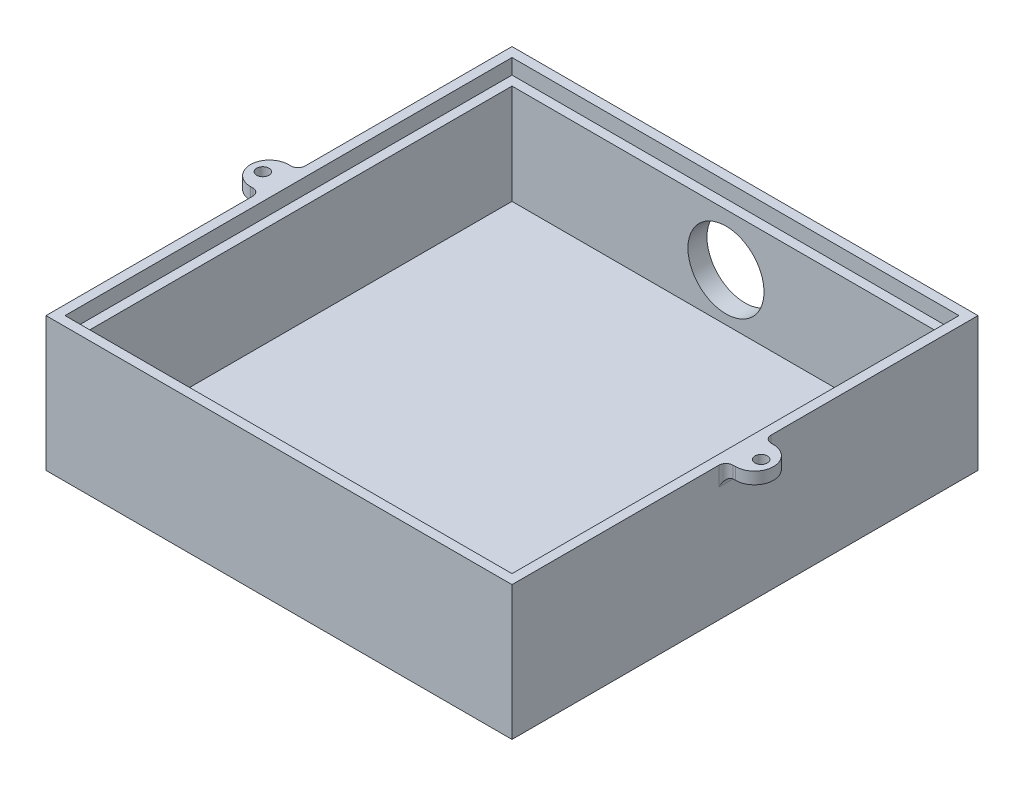
from build123d import *

# Parameters (mm, degrees)
SKETCH1_W           = 98
SKETCH1_H           = 98
BOSS_EXTRUDE1_DEPTH = 30
SKETCH2_W           = 94
SKETCH2_H           = 94
CUT_EXTRUDE1_DEPTH  = 5
SKETCH3_W           = 90
SKETCH3_H           = 90
CUT_EXTRUDE2_DEPTH  = 21
SKETCH4_W           = 98
SKETCH4_H           = 98
SKETCH4_W_2         = 94
SKETCH4_H_2         = 94
CUT_EXTRUDE3_DEPTH  = 1.8
SKETCH5_R           = 1.3
BOSS_EXTRUDE2_DEPTH = 2.5
FILLET1_R           = 1.5
FILLET2_R           = 1.5
CUT_EXTRUDE4_REACH  = 100
SKETCH6_R           = 8
SKETCH7_R           = 1.968352886
CUT_EXTRUDE5_DEPTH  = 1


with BuildPart() as part:
    # Sketch1 → Boss-Extrude1 (new body)
    with BuildSketch(Plane(origin=(0, 0, 0), x_dir=(1, 0, 0), z_dir=(0, 1, 0))):
        Rectangle(SKETCH1_W, SKETCH1_H)
    extrude(amount=BOSS_EXTRUDE1_DEPTH)

    # Sketch2 → Cut-Extrude1 (cut)
    with BuildSketch(Plane(origin=(0, 30, 0), x_dir=(1, 0, 0), z_dir=(0, 1, 0))):
        Rectangle(SKETCH2_W, SKETCH2_H)
    extrude(amount=-CUT_EXTRUDE1_DEPTH, mode=Mode.SUBTRACT)

    # Sketch3 → Cut-Extrude2 (cut)
    with BuildSketch(Plane(origin=(0, 25, 0), x_dir=(1, 0, 0), z_dir=(0, 1, 0))):
        Rectangle(SKETCH3_W, SKETCH3_H)
    extrude(amount=-CUT_EXTRUDE2_DEPTH, mode=Mode.SUBTRACT)

    # Sketch4 → Cut-Extrude3 (cut)
    with BuildSketch(Plane(origin=(0, 30, 0), x_dir=(1, 0, 0), z_dir=(0, 1, 0))):
        Rectangle(SKETCH4_W, SKETCH4_H)
        Rectangle(SKETCH4_W_2, SKETCH4_H_2, mode=Mode.SUBTRACT)
    extrude(amount=-CUT_EXTRUDE3_DEPTH, mode=Mode.SUBTRACT)

    # Sketch5 → Boss-Extrude2 (add)
    with BuildSketch(Plane(origin=(0, 28.2, 0), x_dir=(1, 0, 0), z_dir=(0, 1, 0))):
        with BuildLine():
            Line((-49, 4), (-51, 4))
            ThreePointArc((-51, 4), (-55, 0), (-51, -4))
            Line((-51, -4), (-49, -4))
            Line((-49, -4), (-49, 4))
        make_face()
        with Locations((-52.4, 0)):
            Circle(SKETCH5_R, mode=Mode.SUBTRACT)
        with BuildLine():
            Line((49, 4), (49, -4))
            Line((49, -4), (51, -4))
            ThreePointArc((51, -4), (55, 0), (51, 4))
            Line((51, 4), (49, 4))
        make_face()
        with Locations((52.4, 0)):
            Circle(SKETCH5_R, mode=Mode.SUBTRACT)
    extrude(amount=-BOSS_EXTRUDE2_DEPTH)

    # Fillet1
    fillet1_edges = [part.edges().sort_by_distance(p)[0] for p in [
        (-49, 25.7, 0),
        (-49, 26.95, -4),
        (-49, 26.95, 4),
    ]]
    fillet(fillet1_edges, radius=FILLET1_R)

    # Fillet2
    fillet2_edges = [part.edges().sort_by_distance(p)[0] for p in [
        (49, 26.95, -4),
        (49, 25.7, 0),
        (49, 26.95, 4),
    ]]
    fillet(fillet2_edges, radius=FILLET2_R)

    # Sketch6 → Cut-Extrude4 (cut, up to next)
    with BuildSketch(Plane(origin=(0, 0, -49), x_dir=(-1, 0, 0), z_dir=(0, 0, -1)), mode=Mode.PRIVATE) as cut_extrude4_sk1:
        with Locations((0, 14)):
            Circle(SKETCH6_R)
    cut_extrude4_tool1 = extrude(cut_extrude4_sk1.sketch, amount=-CUT_EXTRUDE4_REACH, mode=Mode.PRIVATE) & part.part
    add(cut_extrude4_tool1.solids().sort_by_distance((0, 14, -49))[0], mode=Mode.SUBTRACT)

    # Sketch7 → Cut-Extrude5 (cut)
    with BuildSketch(Plane.XZ):
        with BuildLine():
            Line((-4, -10), (-1, -10))
            Line((-1, -10), (1, -10))
            ThreePointArc((1, -10), (6, -5), (1, 0))
            ThreePointArc((1, 0), (6, 5), (1, 10))
            Line((1, 10), (-4, 10))
            Line((-4, 10), (-4, -10))
        make_face()
        with Locations((1, 5)):
            Circle(SKETCH7_R, mode=Mode.SUBTRACT)
        with Locations((1, -5)):
            Circle(SKETCH7_R, mode=Mode.SUBTRACT)
    extrude(amount=-CUT_EXTRUDE5_DEPTH, mode=Mode.SUBTRACT)


solid = part.part
